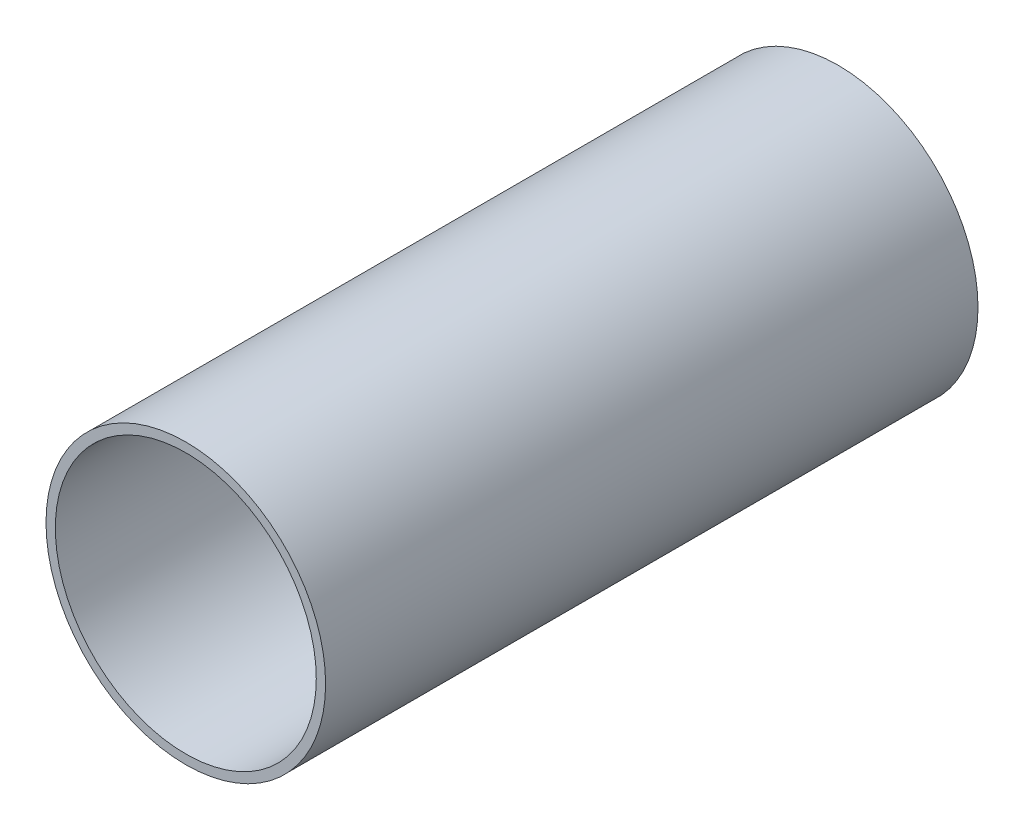
from build123d import *

# Parameters (mm, degrees)
SKETCH1_R           = 15
SKETCH1_R_2         = 14
BOSS_EXTRUDE1_DEPTH = 70


with BuildPart() as part:
    # Sketch1 → Boss-Extrude1 (new body)
    with BuildSketch(Plane.XY):
        Circle(SKETCH1_R)
        Circle(SKETCH1_R_2, mode=Mode.SUBTRACT)
    extrude(amount=BOSS_EXTRUDE1_DEPTH)


solid = part.part
